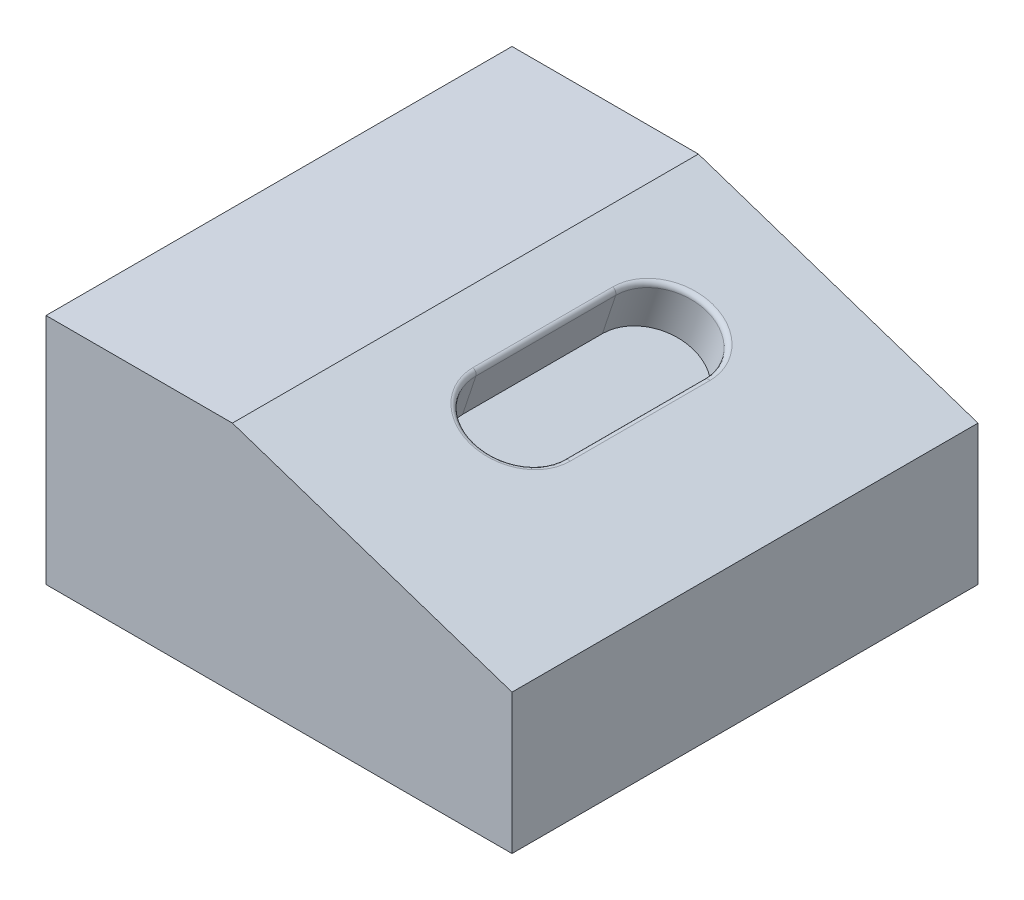
from build123d import *

# Parameters (mm, degrees)
BOSS_EXTRUDE2_DEPTH = 50
CUT_EXTRUDE2_DEPTH  = 5
FILLET1_R           = 0.5


with BuildPart() as part:
    # Sketch1 → Boss-Extrude2 (new body)
    with BuildSketch(Plane.XY):
        Polygon((0, 0), (0, 25), (20, 25), (50, 15), (50, 0), align=None)
    extrude(amount=BOSS_EXTRUDE2_DEPTH)

    # Sketch3 → Cut-Extrude2 (cut)
    with BuildSketch(Plane(origin=(9.5, 28.5, 0), x_dir=(0.948683298, -0.316227766, 0), z_dir=(0.316227766, 0.948683298, 0))):
        with BuildLine():
            Line((17.690748412, -15), (17.690748412, -30))
            ThreePointArc((17.690748412, -30), (22.690748412, -35), (27.690748412, -30))
            Line((27.690748412, -30), (27.690748412, -15))
            ThreePointArc((27.690748412, -15), (22.690748412, -10), (17.690748412, -15))
        make_face()
    extrude(amount=-CUT_EXTRUDE2_DEPTH, mode=Mode.SUBTRACT)

    # Fillet1
    fillet1_edges = [part.edges().sort_by_distance(p)[0] for p in [
        (31.026334039, 21.32455532, 10),
        (26.282917549, 22.90569415, 22.5),
        (31.026334039, 21.32455532, 35),
        (35.769750529, 19.74341649, 22.5),
    ]]
    fillet(fillet1_edges, radius=FILLET1_R)


solid = part.part
